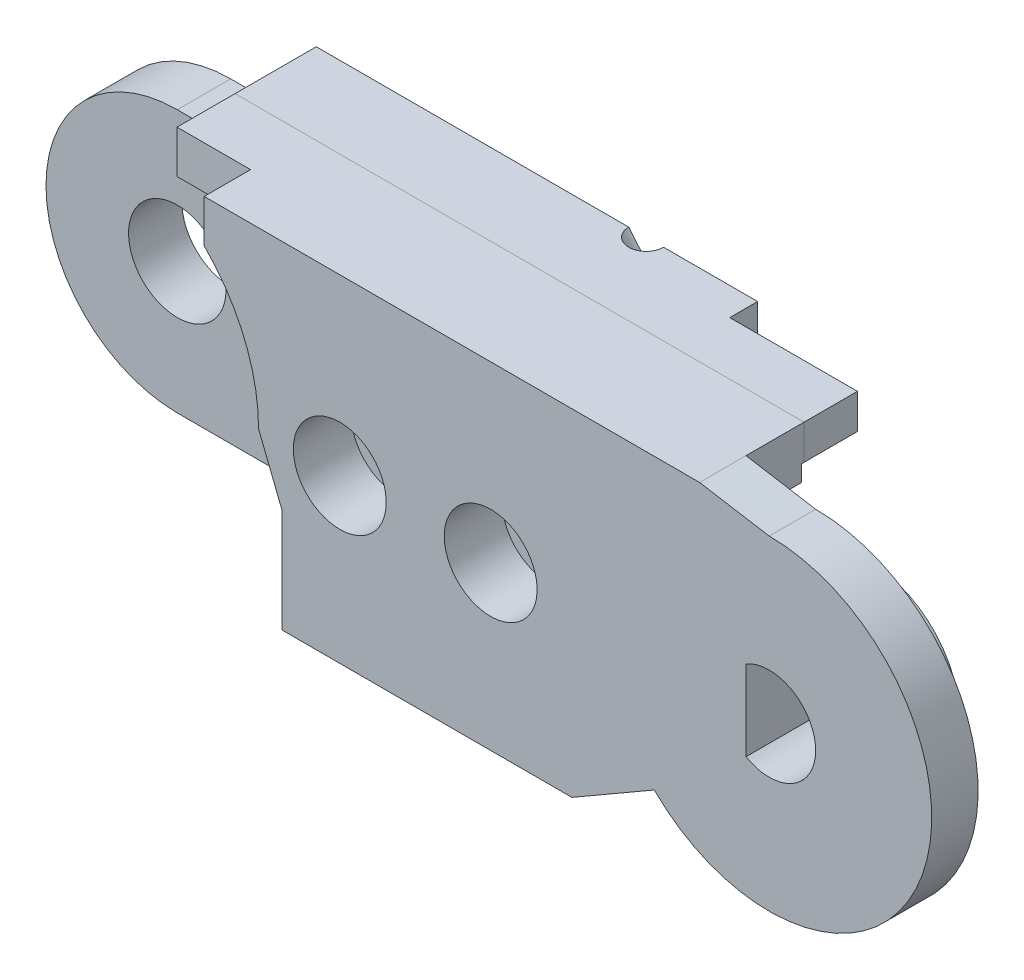
from build123d import *

# Parameters (mm, degrees)
BOSS_EXTRUDE1_DEPTH  = 2
BOSS_EXTRUDE6_DEPTH  = 2.5
CUT_EXTRUDE6_DEPTH   = 2.5
BOSS_EXTRUDE14_DEPTH = 2.3
SKETCH32_R           = 2.1
CUT_EXTRUDE7_DEPTH   = 2.3
SKETCH33_W           = 12.5
SKETCH33_H           = 1.343145751
BOSS_EXTRUDE15_DEPTH = 1.2
SKETCH35_W           = 5.479645997
SKETCH35_H           = 3.827993755
CUT_EXTRUDE8_DEPTH   = 2.4
SKETCH36_W           = 3.7
SKETCH36_H           = 1.827993755
CUT_EXTRUDE9_DEPTH   = 2.4
SKETCH37_R           = 3.9
BOSS_EXTRUDE16_DEPTH = 2.3
CUT_EXTRUDE10_DEPTH  = 5.3
SKETCH43_R           = 2.5
BOSS_EXTRUDE17_DEPTH = 1.2
SKETCH44_R           = 0.95
CUT_EXTRUDE11_DEPTH  = 9
SKETCH45_R           = 2
CUT_EXTRUDE12_DEPTH  = 2.5
SKETCH52_R           = 0.75
CUT_EXTRUDE13_DEPTH  = 10


with BuildPart() as part:
    # Sketch3 → Boss-Extrude1 (new body)
    with BuildSketch(Plane.XY):
        with BuildLine():
            Line((8, 0), (9, -2.5))
            Line((9, -2.5), (9, -7))
            Line((9, -7), (21.5, -7))
            Line((21.5, -7), (25.050252532, -4.949747468))
            ThreePointArc((25.050252532, -4.949747468), (36.467156728, -2.678784027), (30, 7))
            Line((30, 7), (27, 7.5))
            Line((27, 7.5), (5.656854249, 7.5))
            Line((5.656854249, 7.5), (5.656854249, 5.656854249))
            ThreePointArc((5.656854249, 5.656854249), (7.39103626, 3.061467459), (8, 0))
        make_face()
    extrude(amount=BOSS_EXTRUDE1_DEPTH)

    # Sketch22 → Boss-Extrude6 (add)
    with BuildSketch(Plane.XY.offset(2)):
        with BuildLine():
            Line((5.656854249, 5.656854249), (2.486790148, 5.656854249))
            Line((2.486790148, 5.656854249), (2.486790148, 7.5))
            Line((2.486790148, 7.5), (5.656854249, 7.5))
            Line((5.656854249, 7.5), (21.5, 7.5))
            Line((21.5, 7.5), (27, 7.5))
            Line((27, 7.5), (27, 2.172006245))
            Line((27, 2.172006245), (23.275126266, 2.172006245))
            Line((23.275126266, 2.172006245), (23.275126266, -5.974873734))
            Line((23.275126266, -5.974873734), (21.5, -7))
            Line((21.5, -7), (9, -7))
            Line((9, -7), (9, -2.5))
            Line((9, -2.5), (8, 0))
            ThreePointArc((8, 0), (7.39103626, 3.061467459), (5.656854249, 5.656854249))
        make_face()
    extrude(amount=BOSS_EXTRUDE6_DEPTH)

    # Sketch26 → Cut-Extrude6 (cut)
    with BuildSketch(Plane.XY.offset(2)):
        Polygon((18.098080448, 5.3), (2.530052458, 5.3), (2.530052458, 4), (18.098080448, 4), (27, 4), (27, 5.3), align=None)
    extrude(amount=CUT_EXTRUDE6_DEPTH, mode=Mode.SUBTRACT)


with BuildPart() as body_2:
    # Sketch31 → Boss-Extrude14 (new body)
    with BuildSketch(Plane.XY.offset(4.5)):
        with BuildLine():
            Line((2.432688066, 5.656854249), (0, 5.656854249))
            ThreePointArc((0, 5.656854249), (-5.656854249, 0), (0, -5.656854249))
            Line((0, -5.656854249), (9, -5.656854249))
            Line((9, -5.656854249), (9, -7))
            Line((9, -7), (21.5, -7))
            Line((21.5, -7), (23.275126266, -5.974873734))
            Line((23.275126266, -5.974873734), (23.275126266, 2.172006245))
            Line((23.275126266, 2.172006245), (27, 2.172006245))
            Line((27, 2.172006245), (27, 7.5))
            Line((27, 7.5), (2.486790148, 7.5))
            Line((2.486790148, 7.5), (2.432688066, 5.656854249))
        make_face()
    extrude(amount=BOSS_EXTRUDE14_DEPTH)

    # Sketch32 → Cut-Extrude7 (cut)
    with BuildSketch(Plane.XY.offset(6.8)):
        Circle(SKETCH32_R)
    extrude(amount=-CUT_EXTRUDE7_DEPTH, mode=Mode.SUBTRACT)

    # Sketch33 → Boss-Extrude15 (add)
    with BuildSketch(Plane.XY.offset(6.8)):
        with Locations((15.25, -6.328427125)):
            Rectangle(SKETCH33_W, SKETCH33_H)
        Polygon((2.486790148, 7.5), (21.5, 7.5), (21.5, 5.656854249), (2.432688066, 5.656854249), align=None)
    extrude(amount=BOSS_EXTRUDE15_DEPTH)


with BuildPart() as cut_extrude8_tool:
    # Sketch35 → Cut-Extrude8 (new body)
    with BuildSketch(Plane.XY.offset(6.8)):
        with Locations((24.260177002, 4.086003123)):
            Rectangle(SKETCH35_W, SKETCH35_H)
    extrude(amount=-CUT_EXTRUDE8_DEPTH)


with BuildPart() as part_1:
    add(part.part)

    # Cut-Extrude8: cut by cut_extrude8_tool
    add(cut_extrude8_tool.part, mode=Mode.SUBTRACT)

    # Sketch36 → Cut-Extrude9 (cut)
    with BuildSketch(Plane.XY.offset(4.4)):
        with Locations((25.15, 3.086003123)):
            Rectangle(SKETCH36_W, SKETCH36_H)
    extrude(amount=-CUT_EXTRUDE9_DEPTH, mode=Mode.SUBTRACT)

    # Sketch37 → Boss-Extrude16 (add)
    with BuildSketch(Plane.XY.offset(2)):
        with Locations((30, 0)):
            Circle(SKETCH37_R)
    extrude(amount=BOSS_EXTRUDE16_DEPTH)

    # Sketch39 → Cut-Extrude10 (cut, through all)
    with BuildSketch(Plane.XY.offset(4.3)):
        with BuildLine():
            Line((29, 1.732050808), (29, -1.732050808))
            ThreePointArc((29, -1.732050808), (32, 0), (29, 1.732050808))
        make_face()
    extrude(amount=-CUT_EXTRUDE10_DEPTH, mode=Mode.SUBTRACT)


with BuildPart() as body_2_1:
    add(body_2.part)

    # Cut-Extrude8: cut by cut_extrude8_tool
    add(cut_extrude8_tool.part, mode=Mode.SUBTRACT)

    # Sketch43 → Boss-Extrude17 (add)
    with BuildSketch(Plane.XY.offset(6.8)):
        with Locations((11.5, 0)):
            Circle(SKETCH43_R)
        with Locations((18, 0)):
            Circle(SKETCH43_R)
    extrude(amount=BOSS_EXTRUDE17_DEPTH)


with BuildPart() as cut_extrude11_tool:
    # Sketch44 → Cut-Extrude11 (new body, through all)
    with BuildSketch(Plane.XY.offset(8)):
        with Locations((11.5, 0)):
            Circle(SKETCH44_R)
        with Locations((18, 0)):
            Circle(SKETCH44_R)
    extrude(amount=-CUT_EXTRUDE11_DEPTH)


with BuildPart() as part_2:
    add(part_1.part)

    # Cut-Extrude11: cut by cut_extrude11_tool
    add(cut_extrude11_tool.part, mode=Mode.SUBTRACT)

    # Sketch45 → Cut-Extrude12 (cut)
    with BuildSketch(Plane(origin=(0, 0, 0), x_dir=(-1, 0, 0), z_dir=(0, 0, -1))):
        with Locations((-11.5, 0)):
            Circle(SKETCH45_R)
        with Locations((-18, 0)):
            Circle(SKETCH45_R)
    extrude(amount=-CUT_EXTRUDE12_DEPTH, mode=Mode.SUBTRACT)


with BuildPart() as body_2_2:
    add(body_2_1.part)

    # Cut-Extrude11: cut by cut_extrude11_tool
    add(cut_extrude11_tool.part, mode=Mode.SUBTRACT)

    # Sketch52 → Cut-Extrude13 (cut, along a direction that is not the sketch's normal)
    with BuildSketch(Plane.XZ.offset(-5.656854249)):
        with Locations((18.235476819, 8)):
            Circle(SKETCH52_R)
    extrude(amount=-CUT_EXTRUDE13_DEPTH, dir=(0.640410196, -0.76803306, 0), mode=Mode.SUBTRACT)


with BuildPart() as body_3:
    # Mirror1: mirrored copy
    add(body_2_2.part.mirror(Plane.XY.offset(8)))


with BuildPart() as body_4:
    # Mirror1 2: mirrored copy
    add(part_2.part.mirror(Plane.XY.offset(8)))


solid = Compound([body_3.part, body_4.part])
